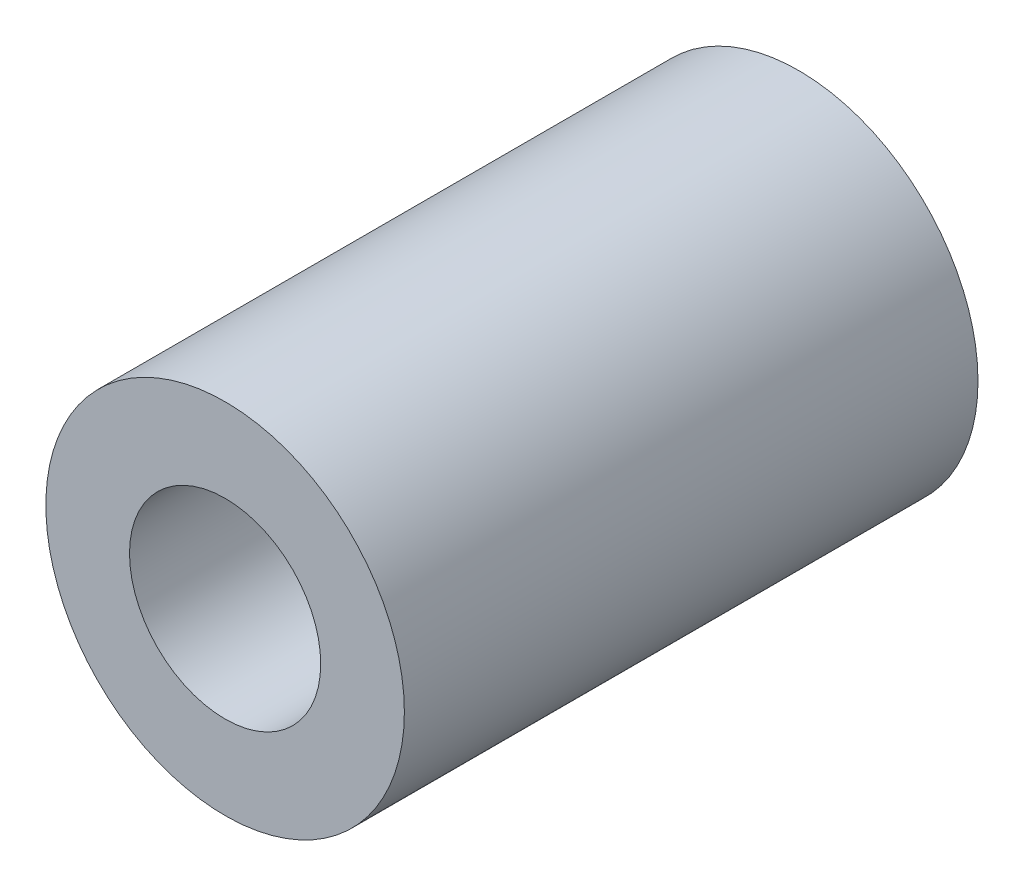
from build123d import *

# Parameters (mm, degrees)
ESBO_O1_R                = 7.5
ESBO_O1_R_2              = 4
RESSALTO_EXTRUS_O1_DEPTH = 24


with BuildPart() as part:
    # Esboço1 → Ressalto-extrusão1 (new body)
    with BuildSketch(Plane.XY):
        Circle(ESBO_O1_R)
        Circle(ESBO_O1_R_2, mode=Mode.SUBTRACT)
    extrude(amount=RESSALTO_EXTRUS_O1_DEPTH)


solid = part.part
